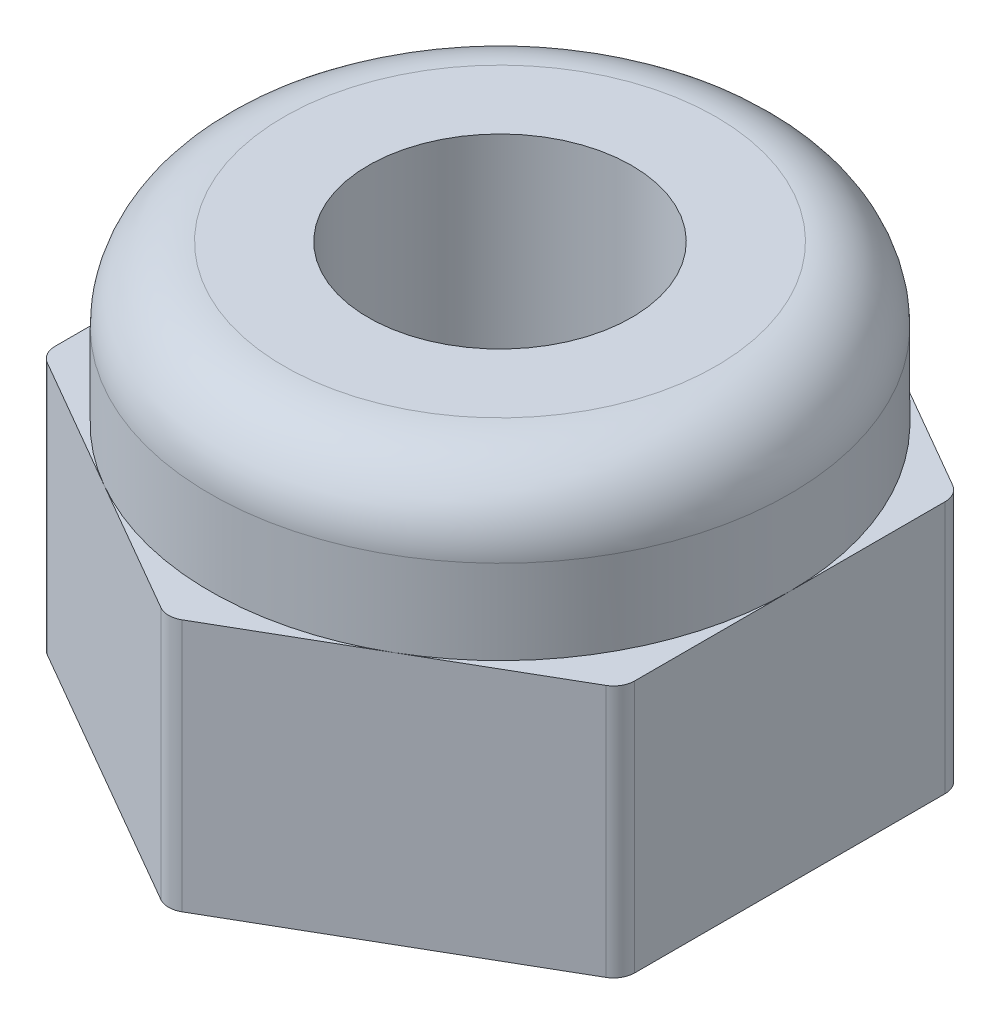
from build123d import *

# Parameters (mm, degrees)
EXTRUDE_1_DEPTH              = 2.4
SKETCH_2_R                   = 2.75
EXTRUDE_2_DEPTH              = 3.9
FILLET_1_R                   = 0.7
FILLET_2_R                   = 0.2
HOLE_WIZARD_M3_1_D           = 2.5
HOLE_WIZARD_M3_1_DEPTH       = 7.5
HOLE_WIZARD_M3_1_CSINK_D     = 3.05
HOLE_WIZARD_M3_1_CSINK_ANGLE = 90
HOLE_WIZARD_M3_1_TIP         = 0.751075774


with BuildPart() as part:
    # 草图1 → 凸台-拉伸1 (new body)
    with BuildSketch(Plane(origin=(0, 0, 0), x_dir=(1, 0, 0), z_dir=(0, 1, 0))):
        Polygon((2.75, -1.58771324), (2.75, 1.58771324), (0, 3.175426481), (-2.75, 1.58771324), (-2.75, -1.58771324), (0, -3.175426481), align=None)
    extrude(amount=EXTRUDE_1_DEPTH)

    # 草图2 → 凸台-拉伸2 (add)
    with BuildSketch(Plane.XZ):
        Circle(SKETCH_2_R)
    extrude(amount=-EXTRUDE_2_DEPTH)

    # 圆角1
    fillet_1_edges = [part.edges().sort_by_distance(p)[0] for p in [
        (-2.75, 3.9, 0),
    ]]
    fillet(fillet_1_edges, radius=FILLET_1_R)

    # 圆角2
    fillet_2_edges = [part.edges().sort_by_distance(p)[0] for p in [
        (0, 1.2, 3.175426481),
        (-2.75, 1.2, 1.58771324),
        (-2.75, 1.2, -1.58771324),
        (0, 1.2, -3.175426481),
        (2.75, 1.2, -1.58771324),
        (2.75, 1.2, 1.58771324),
    ]]
    fillet(fillet_2_edges, radius=FILLET_2_R)

    # M3 螺纹孔1
    with Locations(Plane(origin=(0, 0, 0), x_dir=(-1, 0, 0), z_dir=(0, -1, 0))):
        with Locations((0, 0)):
            CounterSinkHole(HOLE_WIZARD_M3_1_D / 2, HOLE_WIZARD_M3_1_CSINK_D / 2, depth=HOLE_WIZARD_M3_1_DEPTH, counter_sink_angle=HOLE_WIZARD_M3_1_CSINK_ANGLE)
            with Locations((0, 0, -(HOLE_WIZARD_M3_1_DEPTH + HOLE_WIZARD_M3_1_TIP / 2))):  # 118° drill point
                Cone(0, HOLE_WIZARD_M3_1_D / 2, HOLE_WIZARD_M3_1_TIP, mode=Mode.SUBTRACT)


solid = part.part
